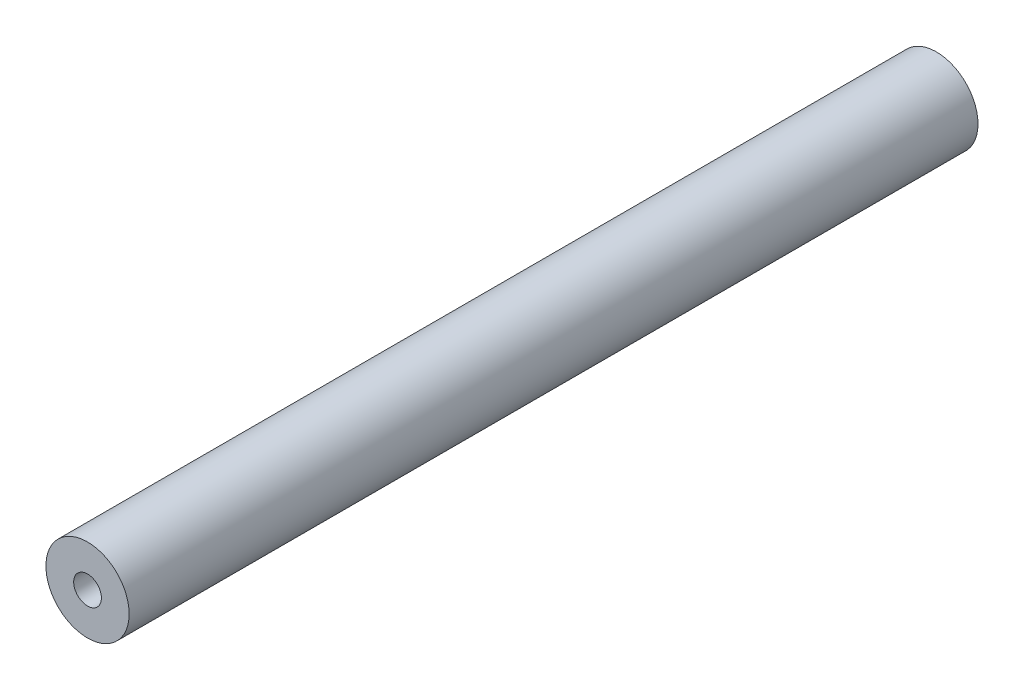
from build123d import *

# Parameters (mm, degrees)
SKETCH1_R           = 38.1
SKETCH1_R_2         = 12.7
BOSS_EXTRUDE1_DEPTH = 777.24


with BuildPart() as part:
    # Sketch1 → Boss-Extrude1 (new body)
    with BuildSketch(Plane.XY):
        Circle(SKETCH1_R)
        Circle(SKETCH1_R_2, mode=Mode.SUBTRACT)
    extrude(amount=BOSS_EXTRUDE1_DEPTH)


solid = part.part
